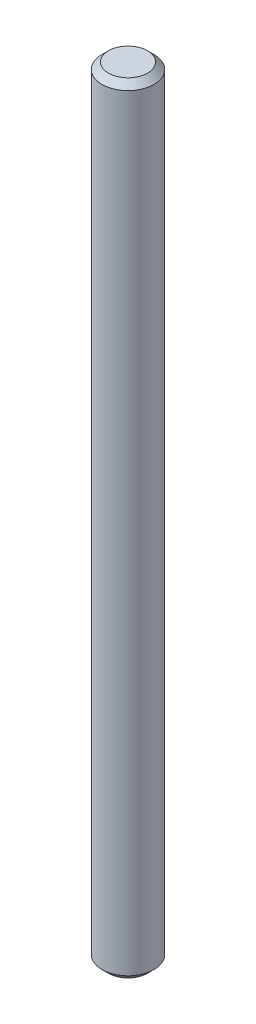
from build123d import *

# Parameters (mm, degrees)
SKETCH_1_R      = 4
EXTRUDE_1_DEPTH = 120
CHAMFER_1_SIZE  = 1


with BuildPart() as part:
    # 草圖1 → 填料-伸長1 (new body)
    with BuildSketch(Plane(origin=(0, 0, 0), x_dir=(1, 0, 0), z_dir=(0, 1, 0))):
        Circle(SKETCH_1_R)
    extrude(amount=EXTRUDE_1_DEPTH)

    # 導角1
    chamfer_1_edges = [part.edges().sort_by_distance(p)[0] for p in [
        (-4, 0, 0),
        (-4, 120, 0),
    ]]
    chamfer(chamfer_1_edges, length=CHAMFER_1_SIZE)


solid = part.part
